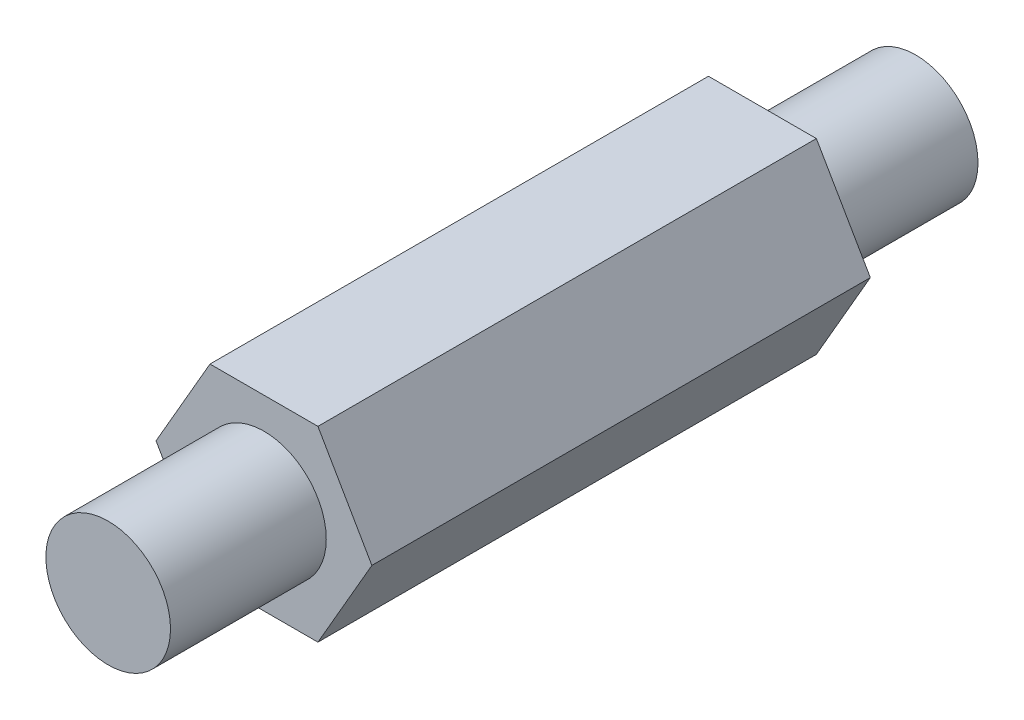
from build123d import *

# Parameters (mm, degrees)
BOSS_EXTRUDE1_DEPTH = 41.148
SKETCH2_OUTSIDE_W   = 21.726
SKETCH2_OUTSIDE_H   = 20.254
SKETCH2_OUTSIDE_R   = 3.175
CUT_EXTRUDE1_DEPTH  = 7.9375
SKETCH3_OUTSIDE_W   = 21.726
SKETCH3_OUTSIDE_H   = 20.254
SKETCH3_OUTSIDE_R   = 3.175
CUT_EXTRUDE2_DEPTH  = 8.8105


with BuildPart() as part:
    # Sketch1 → Boss-Extrude1 (new body)
    with BuildSketch(Plane.XY):
        Polygon((-2.749630657, -4.7625), (2.749630657, -4.7625), (5.499261314, 0), (2.749630657, 4.7625), (-2.749630657, 4.7625), (-5.499261314, 0), align=None)
    extrude(amount=BOSS_EXTRUDE1_DEPTH)

    # Sketch2 outside → Cut-Extrude1 (cut)
    with BuildSketch(Plane.XY.offset(41.148)):
        Rectangle(SKETCH2_OUTSIDE_W, SKETCH2_OUTSIDE_H)
        Circle(SKETCH2_OUTSIDE_R, mode=Mode.SUBTRACT)
    extrude(amount=-CUT_EXTRUDE1_DEPTH, mode=Mode.SUBTRACT)

    # Sketch3 outside → Cut-Extrude2 (cut, through all)
    with BuildSketch(Plane.XY.offset(7.8105)):
        Rectangle(SKETCH3_OUTSIDE_W, SKETCH3_OUTSIDE_H)
        Circle(SKETCH3_OUTSIDE_R, mode=Mode.SUBTRACT)
    extrude(amount=-CUT_EXTRUDE2_DEPTH, mode=Mode.SUBTRACT)


solid = part.part
